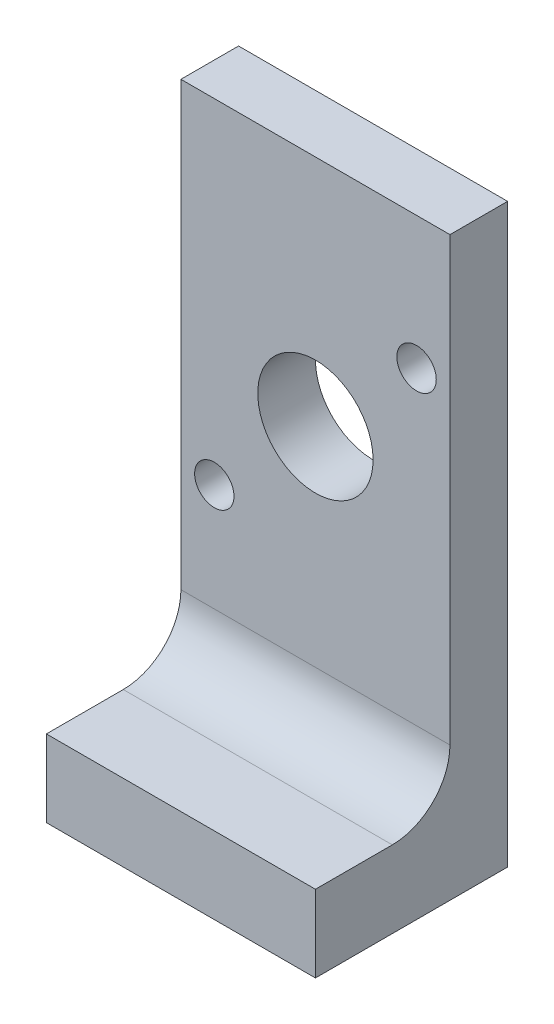
from build123d import *

# Parameters (mm, degrees)
BOSS_EXTRUDE1_DEPTH                = 14
TAP_DRILL_FOR_M3X0_5_TAP1_D        = 2.5
TAP_DRILL_FOR_M3X0_5_TAP1_DEPTH    = 3
TAP_DRILL_FOR_M3X0_5_TAP1_TIP      = 0.751075774
CUT_EXTRUDE1_REACH                 = 5
SKETCH4_R                          = 3
TAP_DRILL_FOR_M2_5X0_45_TAP1_D     = 2.05
TAP_DRILL_FOR_M2_5X0_45_TAP1_DEPTH = 3


with BuildPart() as part:
    # Sketch1 → Boss-Extrude1 (new body)
    with BuildSketch(Plane(origin=(0, 0, 0), x_dir=(0, 0, -1), z_dir=(1, 0, 0))):
        with BuildLine():
            Line((0, 0), (10, 0))
            Line((10, 0), (10, 30))
            Line((10, 30), (7, 30))
            Line((7, 30), (7, 7))
            ThreePointArc((7, 7), (6.121320344, 4.878679656), (4, 4))
            Line((4, 4), (0, 4))
            Line((0, 4), (0, 0))
        make_face()
    extrude(amount=BOSS_EXTRUDE1_DEPTH)

    # Tap Drill for M3x0.5 Tap1
    with Locations(Plane(origin=(0, 0, 0), x_dir=(-1, 0, 0), z_dir=(0, -1, 0))):
        with Locations((-11, 7), (-3, 3)):
            Hole(TAP_DRILL_FOR_M3X0_5_TAP1_D / 2, depth=TAP_DRILL_FOR_M3X0_5_TAP1_DEPTH)
            with Locations((0, 0, -(TAP_DRILL_FOR_M3X0_5_TAP1_DEPTH + TAP_DRILL_FOR_M3X0_5_TAP1_TIP / 2))):  # 118° drill point
                Cone(0, TAP_DRILL_FOR_M3X0_5_TAP1_D / 2, TAP_DRILL_FOR_M3X0_5_TAP1_TIP, mode=Mode.SUBTRACT)

    # Sketch4 → Cut-Extrude1 (cut, up to next)
    with BuildSketch(Plane.XY.offset(-7), mode=Mode.PRIVATE) as cut_extrude1_sk1:
        with Locations((7, 17.85)):
            Circle(SKETCH4_R)
    cut_extrude1_tool1 = extrude(cut_extrude1_sk1.sketch, amount=-CUT_EXTRUDE1_REACH, mode=Mode.PRIVATE) & part.part
    add(cut_extrude1_tool1.solids().sort_by_distance((7, 17.85, -7))[0], mode=Mode.SUBTRACT)

    # Tap Drill for M2.5x0.45 Tap1
    with Locations(Plane.XY.offset(-7)):
        with Locations((1.737569913, 12.587569913), (12.262430087, 23.112430087)):
            Hole(TAP_DRILL_FOR_M2_5X0_45_TAP1_D / 2, depth=TAP_DRILL_FOR_M2_5X0_45_TAP1_DEPTH)


solid = part.part
